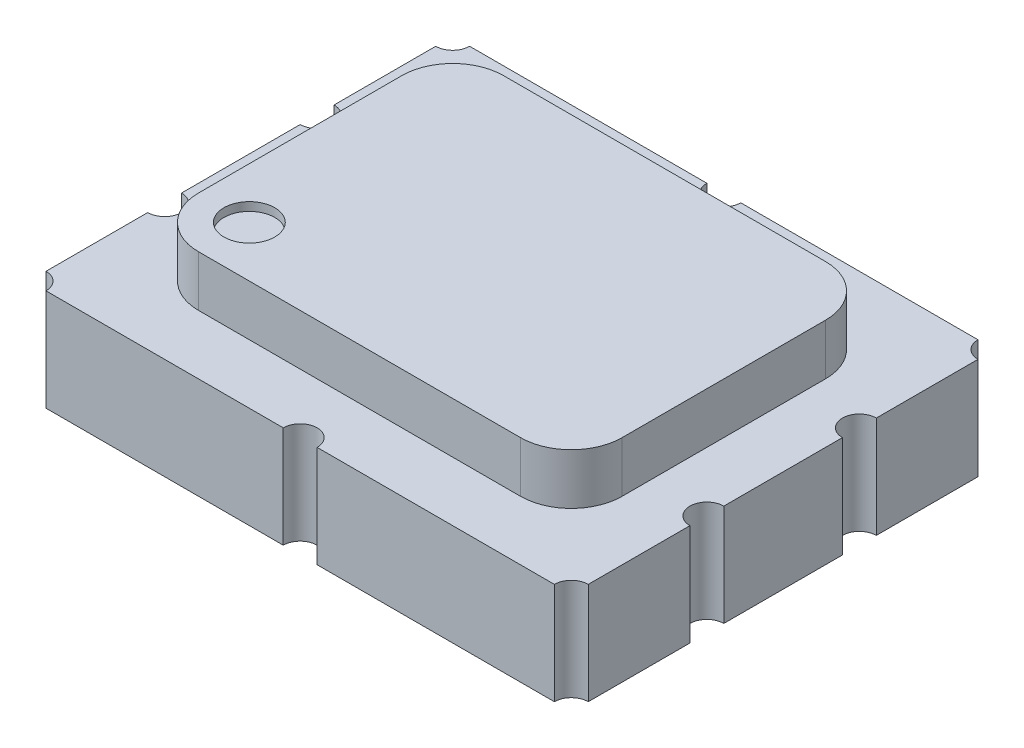
from build123d import *

# Parameters (mm, degrees)
SKETCH1_W           = 3.2
SKETCH1_H           = 2.5
BOSS_EXTRUDE1_DEPTH = 0.6
BOSS_EXTRUDE2_DEPTH = 0.3
SKETCH3_R           = 0.1
CUT_EXTRUDE1_DEPTH  = 1.6
SKETCH4_R           = 0.15
CUT_EXTRUDE2_DEPTH  = 0.05


with BuildPart() as part:
    # Sketch1 → Boss-Extrude1 (new body)
    with BuildSketch(Plane(origin=(0, 0, 0), x_dir=(1, 0, 0), z_dir=(0, 1, 0))):
        Rectangle(SKETCH1_W, SKETCH1_H)
    extrude(amount=BOSS_EXTRUDE1_DEPTH)

    # Sketch2 → Boss-Extrude2 (add)
    with BuildSketch(Plane(origin=(0, 0.6, 0), x_dir=(1, 0, 0), z_dir=(0, 1, 0))):
        with BuildLine():
            Line((-0.95, -0.9), (0.95, -0.9))
            ThreePointArc((0.95, -0.9), (1.162132034, -0.812132034), (1.25, -0.6))
            Line((1.25, -0.6), (1.25, 0.6))
            ThreePointArc((1.25, 0.6), (1.162132034, 0.812132034), (0.95, 0.9))
            Line((0.95, 0.9), (-0.95, 0.9))
            ThreePointArc((-0.95, 0.9), (-1.162132034, 0.812132034), (-1.25, 0.6))
            Line((-1.25, 0.6), (-1.25, -0.6))
            ThreePointArc((-1.25, -0.6), (-1.162132034, -0.812132034), (-0.95, -0.9))
        make_face()
    extrude(amount=BOSS_EXTRUDE2_DEPTH)

    # Sketch3 → Cut-Extrude1 (cut, through all)
    with BuildSketch(Plane(origin=(0, 0.6, 0), x_dir=(1, 0, 0), z_dir=(0, 1, 0))):
        with Locations((-1.6, 1.25)):
            Circle(SKETCH3_R)
        with Locations((0, 1.25)):
            Circle(SKETCH3_R)
        with Locations((1.6, 1.25)):
            Circle(SKETCH3_R)
        with Locations((0, -1.25)):
            Circle(SKETCH3_R)
        with Locations((-1.6, -1.25)):
            Circle(SKETCH3_R)
        with Locations((1.6, -1.25)):
            Circle(SKETCH3_R)
        with Locations((-1.6, 0.45)):
            Circle(SKETCH3_R)
        with Locations((-1.6, -0.45)):
            Circle(SKETCH3_R)
        with Locations((1.6, -0.45)):
            Circle(SKETCH3_R)
        with Locations((1.6, 0.45)):
            Circle(SKETCH3_R)
    extrude(amount=-CUT_EXTRUDE1_DEPTH, mode=Mode.SUBTRACT)

    # Sketch4 → Cut-Extrude2 (cut)
    with BuildSketch(Plane(origin=(0, 0.9, 0), x_dir=(1, 0, 0), z_dir=(0, 1, 0))):
        with Locations((-0.95, -0.6)):
            Circle(SKETCH4_R)
    extrude(amount=-CUT_EXTRUDE2_DEPTH, mode=Mode.SUBTRACT)


solid = part.part
